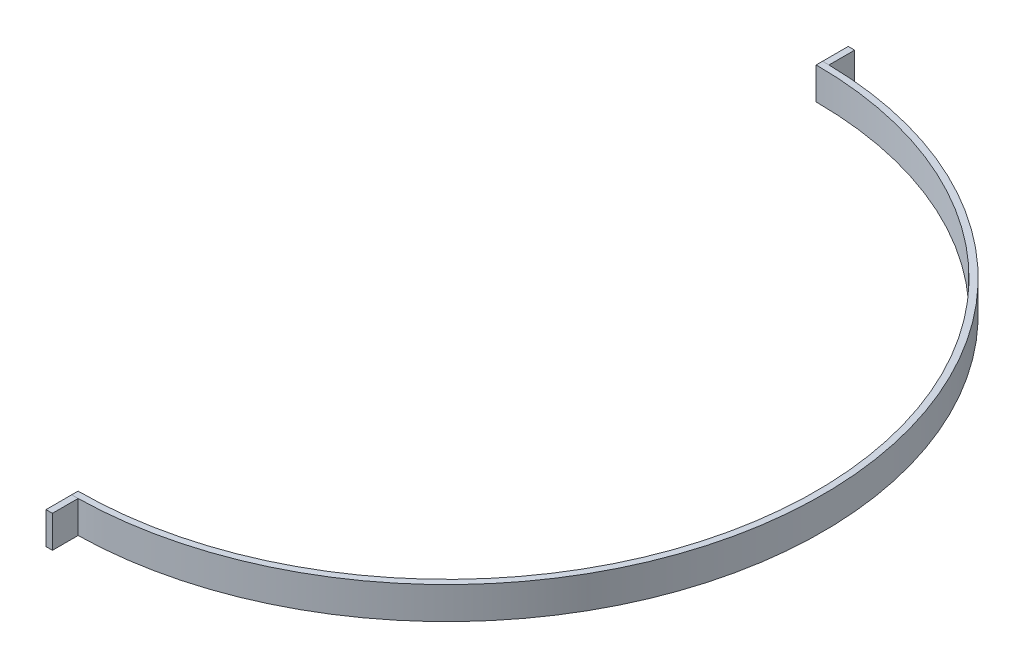
from build123d import *

# Parameters (mm, degrees)
BOSS_EXTRUDE1_DEPTH   = 10
BOSS_EXTRUDE1_2_DEPTH = 10
BOSS_EXTRUDE1_3_DEPTH = 10


with BuildPart() as part:
    # Sketch1 → Boss-Extrude1 (new body)
    with BuildSketch(Plane(origin=(0, 0, 0), x_dir=(1, 0, 0), z_dir=(0, 1, 0))):
        with BuildLine():
            Line((2, 116.982904734), (0, 117))
            Line((0, 117), (0, 115))
            ThreePointArc((0, 115), (81.317279836, 81.317279836), (115, 0))
            ThreePointArc((115, 0), (81.317279836, -81.317279836), (0, -115))
            Line((0, -115), (0, -117))
            Line((0, -117), (2, -116.982904734))
            ThreePointArc((2, -116.982904734), (83.435603911, -82.021338687), (117, 0))
            ThreePointArc((117, 0), (83.435603911, 82.021338687), (2, 116.982904734))
        make_face()
    extrude(amount=BOSS_EXTRUDE1_DEPTH)


with BuildPart() as body_2:
    # Sketch1 → Boss-Extrude1 2 (new body)
    with BuildSketch(Plane(origin=(0, 0, 0), x_dir=(1, 0, 0), z_dir=(0, 1, 0))):
        with BuildLine():
            ThreePointArc((2, -116.982904734), (1.00003653, -116.995726105), (0, -117))
            Line((0, -117), (0, -124.982904734))
            Line((0, -124.982904734), (2, -124.982904734))
            Line((2, -124.982904734), (2, -116.982904734))
        make_face()
    extrude(amount=BOSS_EXTRUDE1_2_DEPTH)


with BuildPart() as body_3:
    # Sketch1 → Boss-Extrude1 3 (new body)
    with BuildSketch(Plane(origin=(0, 0, 0), x_dir=(1, 0, 0), z_dir=(0, 1, 0))):
        with BuildLine():
            Line((0, 124.982904734), (0, 117))
            ThreePointArc((0, 117), (1.00003653, 116.995726105), (2, 116.982904734))
            Line((2, 116.982904734), (2, 124.982904734))
            Line((2, 124.982904734), (0, 124.982904734))
        make_face()
    extrude(amount=BOSS_EXTRUDE1_3_DEPTH)


solid = Compound([part.part, body_2.part, body_3.part])
